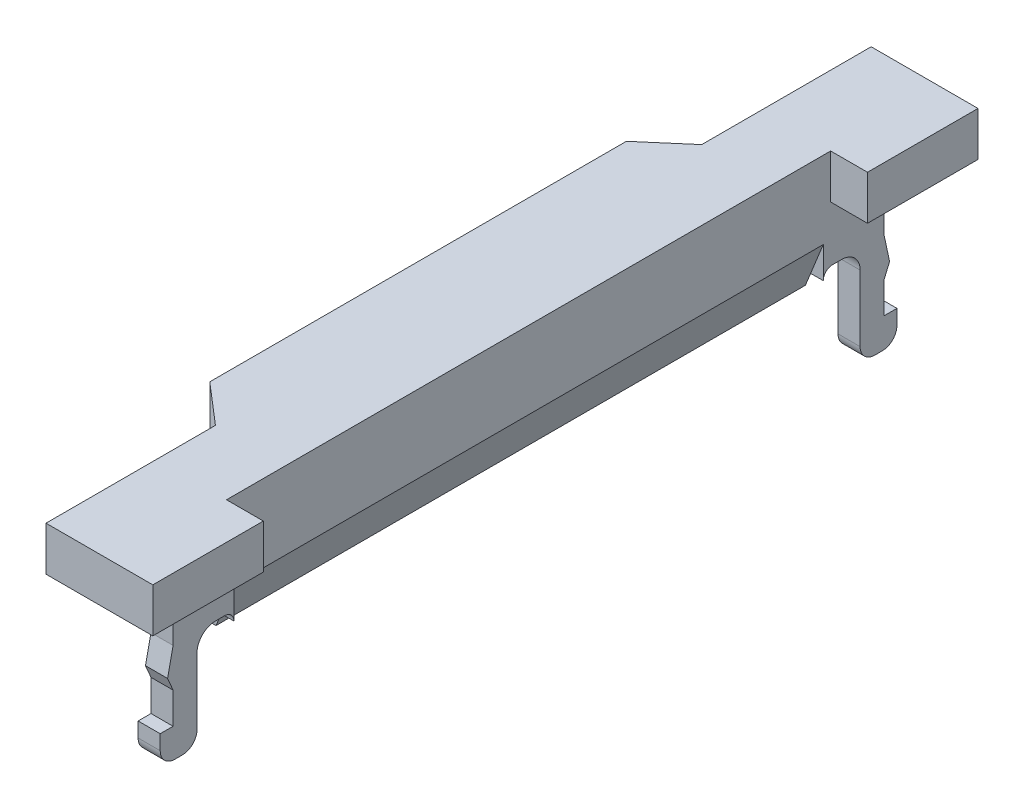
from build123d import *

# Parameters (mm, degrees)
RESSALTO_EXTRUS_O1_DEPTH = 1.2
ESBO_O2_W                = 0.6
ESBO_O2_H                = 16
RESSALTO_EXTRUS_O2_DEPTH = 2.1
CHANFRO1_SIZE            = 1.2
CHANFRO1_SIZE2           = 0.484831471
RESSALTO_EXTRUS_O3_DEPTH = 0.6


with BuildPart() as part:
    # Esboço1 → Ressalto-extrusão1 (new body)
    with BuildSketch(Plane(origin=(0, 0, 0), x_dir=(1, 0, 0), z_dir=(0, 1, 0))):
        Polygon((2, 8.2), (2, 11.2), (-0.9, 11.2), (-0.9, 6.6), (-2, 5.654746766), (-2, -5.654746766), (-0.9, -6.6), (-0.9, -11.2), (2, -11.2), (2, -8.2), (1, -8.2), (1, 8.2), align=None)
    extrude(amount=RESSALTO_EXTRUS_O1_DEPTH)

    # Esboço2 → Ressalto-extrusão2 (add)
    with BuildSketch(Plane.XZ):
        with Locations((0.7, 0)):
            Rectangle(ESBO_O2_W, ESBO_O2_H)
    extrude(amount=RESSALTO_EXTRUS_O2_DEPTH)

    # Chanfro1
    chanfro1_edges = [part.edges().sort_by_distance(p)[0] for p in [
        (1, -2.1, 0),
    ]]
    chanfro1_side = [part.faces().sort_by_distance(p)[0] for p in [
        (1, -0.440540541, 0),
    ]]
    chamfer(chanfro1_edges, length=CHANFRO1_SIZE, length2=CHANFRO1_SIZE2, reference=chanfro1_side[0])

    # Esboço3 → Ressalto-extrusão3 (add)
    with BuildSketch(Plane.ZY.offset(-0.4)):
        with BuildLine():
            Line((-8.25, -1.5), (-8.5, -1.5))
            ThreePointArc((-8.5, -1.5), (-8.853553391, -1.646446609), (-9, -2))
            Line((-9, -2), (-9, -3.8))
            ThreePointArc((-9, -3.8), (-9.117157288, -4.082842712), (-9.4, -4.2))
            Line((-9.4, -4.2), (-9.6, -4.2))
            ThreePointArc((-9.6, -4.2), (-9.882842712, -4.082842712), (-10, -3.8))
            Line((-10, -3.8), (-10, -3.4))
            Line((-10, -3.4), (-9.65, -3.4))
            Line((-9.65, -3.4), (-9.65, -2.55))
            Line((-9.65, -2.55), (-9.8, -2.2))
            Line((-9.8, -2.2), (-9.65, -1.5))
            Line((-9.65, -1.5), (-9.65, -0.7))
            Line((-9.65, -0.7), (-9.85, -0.5))
            Line((-9.85, -0.5), (-9.85, -0.3))
            Line((-9.85, -0.3), (-9.65, 0))
            Line((-9.65, 0), (-8, 0))
            Line((-8, 0), (-8, -1.75))
            ThreePointArc((-8, -1.75), (-8.073223305, -1.573223305), (-8.25, -1.5))
        make_face()
    ressalto_extrus_o3 = extrude(amount=-RESSALTO_EXTRUS_O3_DEPTH)

    # Espelhar1: Ressalto-extrusão3 across plane
    add(ressalto_extrus_o3.mirror(Plane.XY))


solid = part.part
